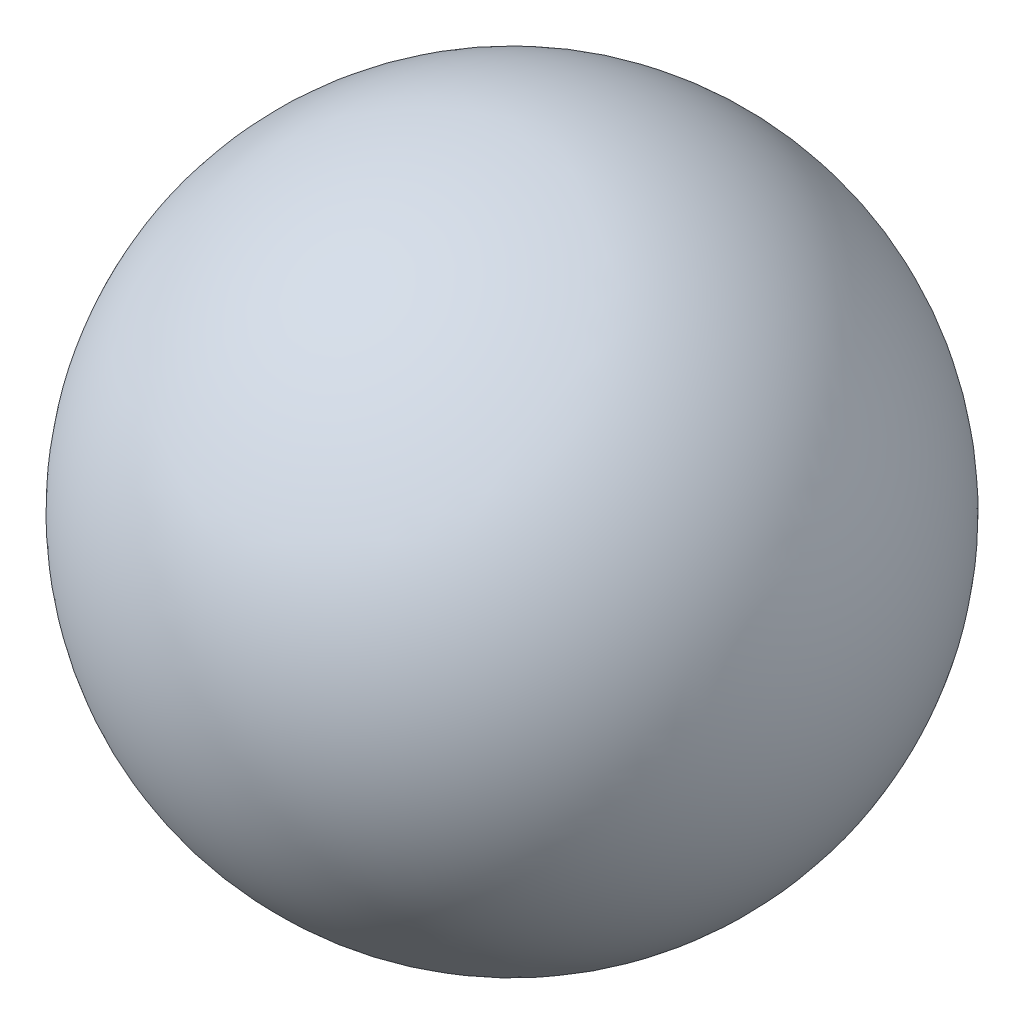
from build123d import *


with BuildPart() as part:
    # Sketch1 → Revolve5 (revolve)
    with BuildSketch(Plane(origin=(0, 0, 0), x_dir=(1, 0, 0), z_dir=(0, 1, 0))):
        with BuildLine():
            Line((-63.5, 0), (63.5, 0))
            ThreePointArc((63.5, 0), (0, -63.5), (-63.5, 0))
        make_face()
    revolve(axis=Axis((-63.5, 0, 0), (1, 0, 0)))


solid = part.part
